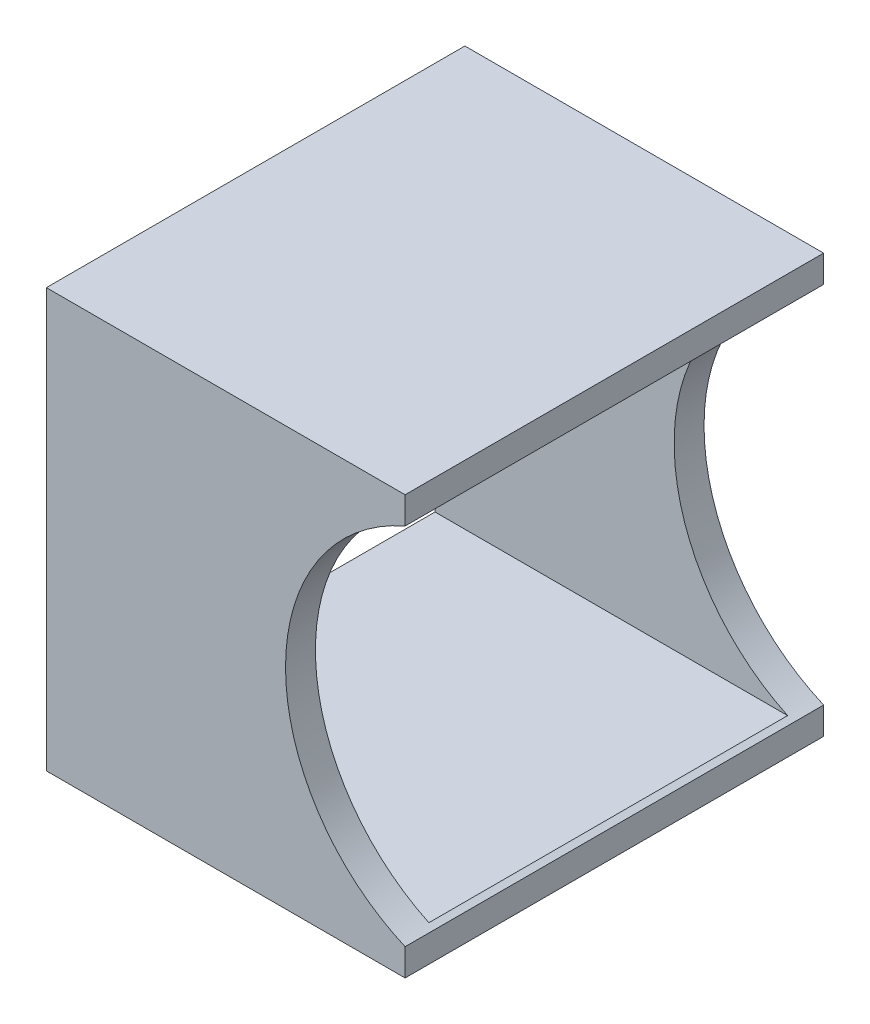
from build123d import *

# Parameters (mm, degrees)
SKETCH1_W               = 44.45
SKETCH1_H               = 44.45
SKETCH1_W_2             = 38.1
SKETCH1_H_2             = 38.1
BOSS_EXTRUDE1_DEPTH     = 38.1
SKETCH2_R               = 21.082
CUT_EXTRUDE1_DEPTH      = 1
CUT_EXTRUDE1_DEPTH_BACK = 45.45


with BuildPart() as part:
    # Sketch1 → Boss-Extrude1 (new body)
    with BuildSketch(Plane(origin=(0, 0, 0), x_dir=(0, 0, -1), z_dir=(1, 0, 0))):
        with Locations((22.225, 22.225)):
            Rectangle(SKETCH1_W, SKETCH1_H)
        with Locations((22.225, 22.225)):
            Rectangle(SKETCH1_W_2, SKETCH1_H_2, mode=Mode.SUBTRACT)
    extrude(amount=BOSS_EXTRUDE1_DEPTH)

    # Sketch2 → Cut-Extrude1 (cut, two sides)
    with BuildSketch(Plane.XY) as cut_extrude1_sk:
        with Locations((46.482, 22.225)):
            Circle(SKETCH2_R)
    extrude(amount=CUT_EXTRUDE1_DEPTH, mode=Mode.SUBTRACT)
    extrude(cut_extrude1_sk.sketch, amount=-CUT_EXTRUDE1_DEPTH_BACK, mode=Mode.SUBTRACT)


solid = part.part
